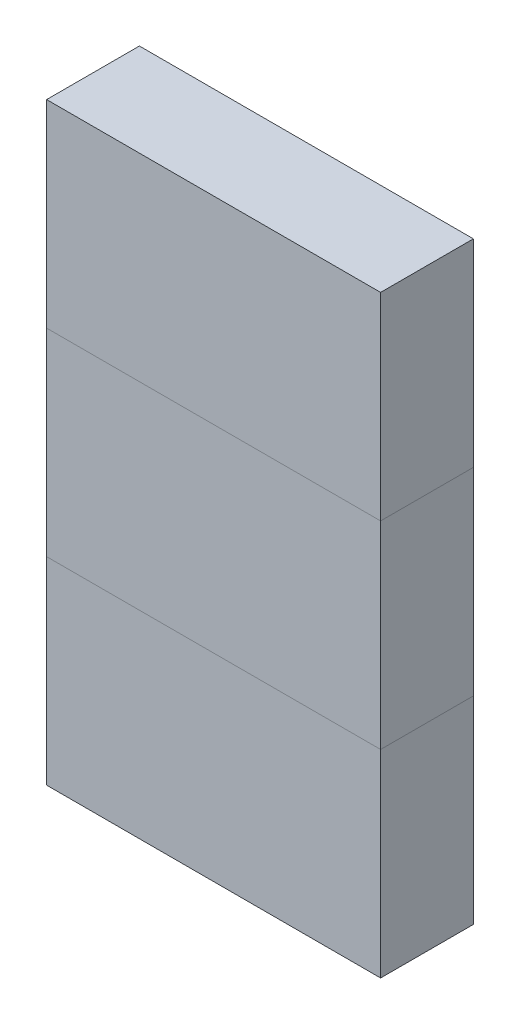
from build123d import *

# Parameters (mm, degrees)
SKETCH1_W                = 57.15
SKETCH1_H                = 15.875
BOSS_EXTRUDE1_DEPTH      = 50.8
SKETCH2_W                = 6.35
SKETCH2_H                = 3.175
SKETCH2_W_2              = 38.1
CUT_EXTRUDE1_DEPTH       = 47.625
SKETCH2_3_W              = 6.35
SKETCH2_3_H              = 3.175
SKETCH2_3_W_2            = 38.1
CUT_EXTRUDE2_DEPTH       = 47.625
SKETCH2_4_W              = 38.1
SKETCH2_4_H              = 3.175
CUT_EXTRUDE3_DEPTH       = 41.275
SPLIT3_SURFACE_1_1_BACK  = 118.646
SPLIT3_SURFACE_1_1_DEPTH = 237.292
SPLIT3_SURFACE_1_2_BACK  = 118.646
SPLIT3_SURFACE_1_2_DEPTH = 237.292
SPLIT3_SURFACE_2_3_BACK  = 118.646
SPLIT3_SURFACE_2_3_DEPTH = 237.292
SPLIT3_SURFACE_2_4_BACK  = 118.646
SPLIT3_SURFACE_2_4_DEPTH = 237.292


with BuildPart() as part:
    # Sketch1 → Boss-Extrude1 (new, symmetric)
    with BuildSketch(Plane(origin=(0, 0, 0), x_dir=(1, 0, 0), z_dir=(0, 1, 0))):
        Rectangle(SKETCH1_W, SKETCH1_H)
    extrude(amount=BOSS_EXTRUDE1_DEPTH, both=True)

    # Sketch2 → Cut-Extrude1 (cut)
    with BuildSketch(Plane(origin=(0, 0, 0), x_dir=(1, 0, 0), z_dir=(0, 1, 0))):
        with Locations((-22.225, 0)):
            Rectangle(SKETCH2_W, SKETCH2_H)
        Rectangle(SKETCH2_W_2, SKETCH2_H)
        with Locations((0, 3.175)):
            Rectangle(SKETCH2_W_2, SKETCH2_H)
        with Locations((0, -3.175)):
            Rectangle(SKETCH2_W_2, SKETCH2_H)
        with Locations((22.225, 0)):
            Rectangle(SKETCH2_W, SKETCH2_H)
    extrude(amount=-CUT_EXTRUDE1_DEPTH, mode=Mode.SUBTRACT)

    # Sketch2_3 → Cut-Extrude2 (cut)
    with BuildSketch(Plane(origin=(0, 0, 0), x_dir=(1, 0, 0), z_dir=(0, 1, 0))):
        with Locations((-22.225, 0)):
            Rectangle(SKETCH2_3_W, SKETCH2_3_H)
        Rectangle(SKETCH2_3_W_2, SKETCH2_3_H)
        with Locations((22.225, 0)):
            Rectangle(SKETCH2_3_W, SKETCH2_3_H)
    extrude(amount=CUT_EXTRUDE2_DEPTH, mode=Mode.SUBTRACT)

    # Sketch2_4 → Cut-Extrude3 (cut)
    with BuildSketch(Plane(origin=(0, 0, 0), x_dir=(1, 0, 0), z_dir=(0, 1, 0))):
        with Locations((0, -3.175)):
            Rectangle(SKETCH2_4_W, SKETCH2_4_H)
        with Locations((0, 3.175)):
            Rectangle(SKETCH2_4_W, SKETCH2_4_H)
    extrude(amount=CUT_EXTRUDE3_DEPTH, mode=Mode.SUBTRACT)


with BuildPart() as body_2:
    # Split3: the piece behind the surface
    add(part.part)
    # Split3 surface 1: a surface, the sketch's curves swept straight by 237.292 mm
    with BuildLine(Plane.XY.offset(-SPLIT3_SURFACE_1_1_BACK), mode=Mode.PRIVATE) as split3_surface_1_1_path:
        Line((28.575, 16.933333333), (-28.575, 16.933333333))
    split3_surface_1_1 = Shell.extrude(split3_surface_1_1_path.wire(), (0 * SPLIT3_SURFACE_1_1_DEPTH, 0 * SPLIT3_SURFACE_1_1_DEPTH, 1 * SPLIT3_SURFACE_1_1_DEPTH))
    split(bisect_by=split3_surface_1_1, keep=Keep.BOTTOM)


with BuildPart() as part_1:
    add(part.part)

    # Split3: split by a surface, the side it looks to stays
    # Split3 surface 1: a surface, the sketch's curves swept straight by 237.292 mm
    with BuildLine(Plane.XY.offset(-SPLIT3_SURFACE_1_2_BACK), mode=Mode.PRIVATE) as split3_surface_1_2_path:
        Line((28.575, 16.933333333), (-28.575, 16.933333333))
    split3_surface_1_2 = Shell.extrude(split3_surface_1_2_path.wire(), (0 * SPLIT3_SURFACE_1_2_DEPTH, 0 * SPLIT3_SURFACE_1_2_DEPTH, 1 * SPLIT3_SURFACE_1_2_DEPTH))
    split(bisect_by=split3_surface_1_2, keep=Keep.TOP)


with BuildPart() as body_3:
    # Split3 2: the piece behind the surface
    add(part_1.part)
    # Split3 surface 2: a surface, the sketch's curves swept straight by 237.292 mm
    with BuildLine(Plane.XY.offset(-SPLIT3_SURFACE_2_3_BACK), mode=Mode.PRIVATE) as split3_surface_2_3_path:
        Line((28.575, -16.933333333), (-28.575, -16.933333333))
    split3_surface_2_3 = Shell.extrude(split3_surface_2_3_path.wire(), (0 * SPLIT3_SURFACE_2_3_DEPTH, 0 * SPLIT3_SURFACE_2_3_DEPTH, 1 * SPLIT3_SURFACE_2_3_DEPTH))
    split(bisect_by=split3_surface_2_3, keep=Keep.BOTTOM)


with BuildPart() as part_2:
    add(part_1.part)

    # Split3 2: split by a surface, the side it looks to stays
    # Split3 surface 2: a surface, the sketch's curves swept straight by 237.292 mm
    with BuildLine(Plane.XY.offset(-SPLIT3_SURFACE_2_4_BACK), mode=Mode.PRIVATE) as split3_surface_2_4_path:
        Line((28.575, -16.933333333), (-28.575, -16.933333333))
    split3_surface_2_4 = Shell.extrude(split3_surface_2_4_path.wire(), (0 * SPLIT3_SURFACE_2_4_DEPTH, 0 * SPLIT3_SURFACE_2_4_DEPTH, 1 * SPLIT3_SURFACE_2_4_DEPTH))
    split(bisect_by=split3_surface_2_4, keep=Keep.TOP)


solid = Compound([body_2.part, body_3.part, part_2.part])
